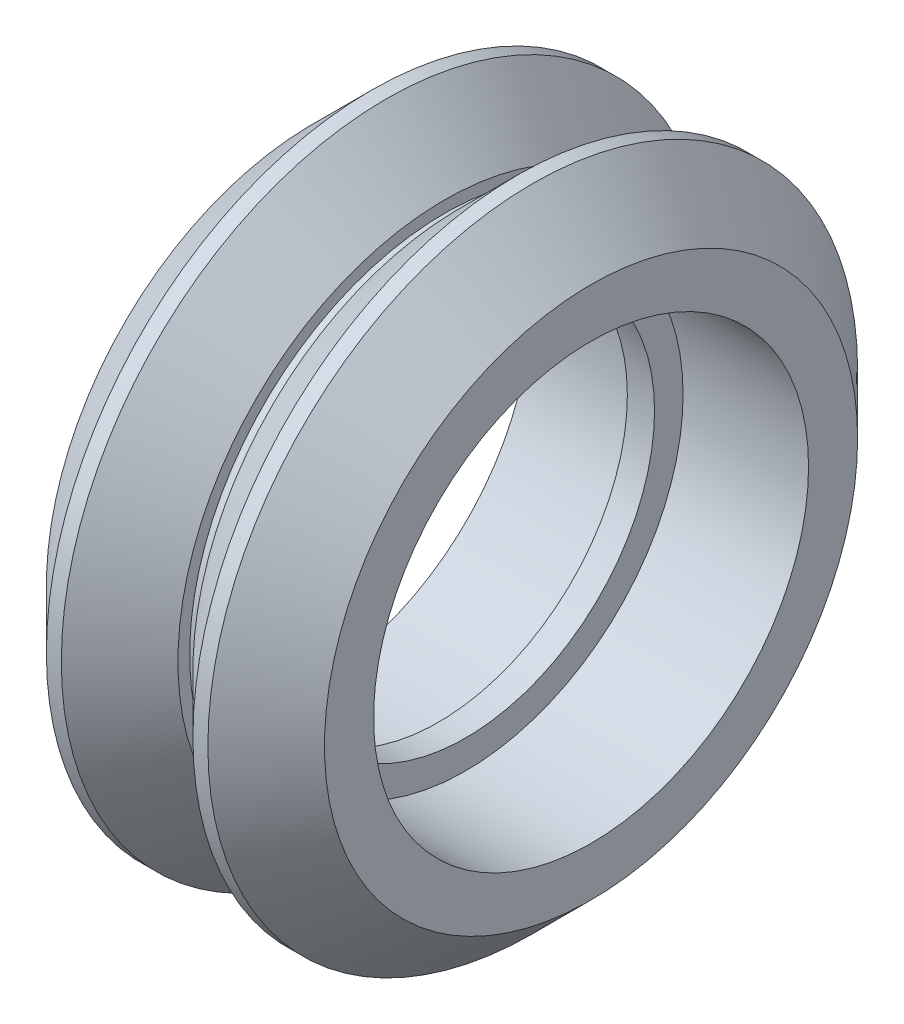
from build123d import *


with BuildPart() as part:
    # Sketch1 → Revolve1 (revolve)
    with BuildSketch(Plane.XY):
        Polygon((0.5, 6.95), (-0.5, 6.95), (-0.5, 8), (-5.115, 8), (-5.115, 9.805), (-2.97, 11.95), (-2.42, 11.95), (-0.275, 9.805), (-0.275, 9.375), (0.275, 9.375), (0.275, 9.805), (2.42, 11.95), (2.97, 11.95), (5.115, 9.805), (5.115, 8), (0.5, 8), align=None)
    revolve(axis=Axis((0, 0, 0), (-1, 0, 0)))


solid = part.part
